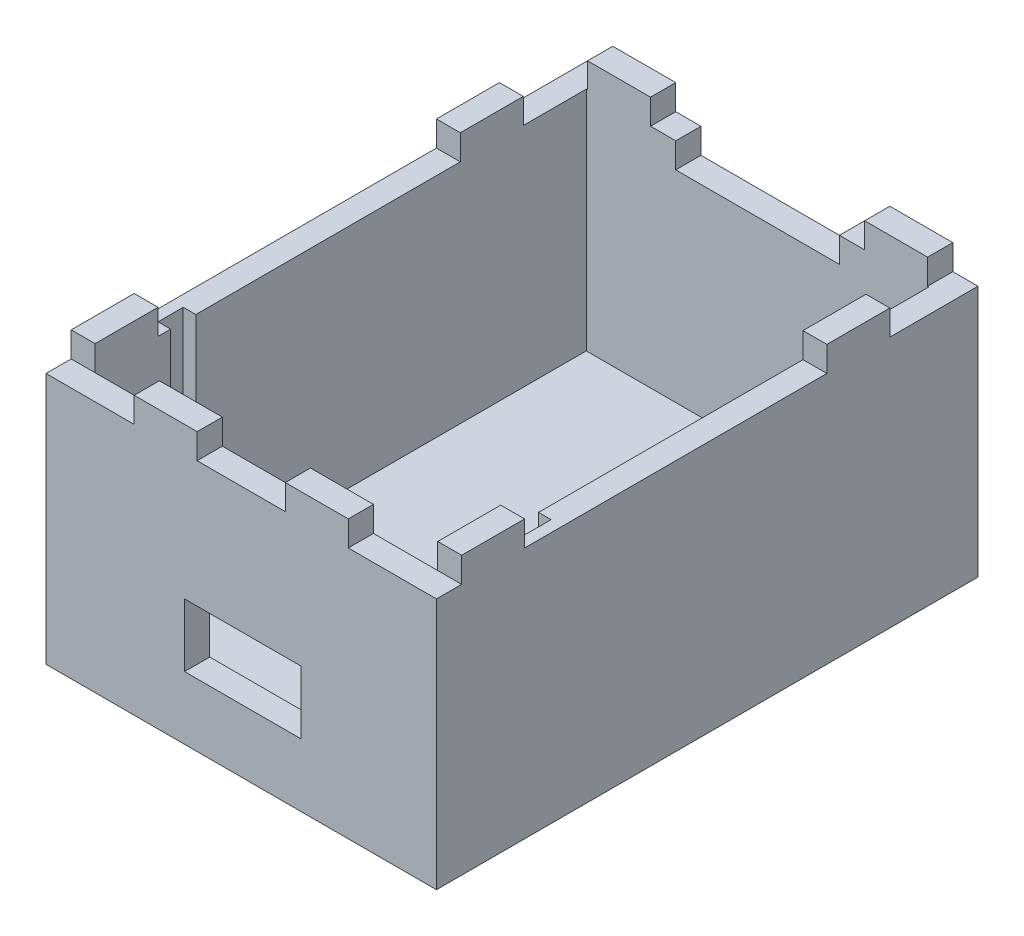
from build123d import *

# Parameters (mm, degrees)
SKETCH1_W           = 31
SKETCH1_H           = 43
BOSS_EXTRUDE1_DEPTH = 22
SKETCH2_W           = 27.20800305
SKETCH2_H           = 39
CUT_EXTRUDE1_DEPTH  = 20
SKETCH3_W           = 9.254141904
SKETCH3_H           = 5
CUT_EXTRUDE2_DEPTH  = 20
SKETCH4_W           = 7
SKETCH4_H           = 2
CUT_EXTRUDE3_DEPTH  = 2
SKETCH5_W           = 2
SKETCH5_H           = 2
CUT_EXTRUDE6_DEPTH  = 2
SKETCH6_W           = 5
SKETCH6_H           = 2
SKETCH6_W_2         = 19
CUT_EXTRUDE10_DEPTH = 34
SKETCH10_W          = 1
SKETCH10_H          = 2
CUT_EXTRUDE11_DEPTH = 18
SKETCH11_W          = 1
SKETCH11_H          = 2
CUT_EXTRUDE12_DEPTH = 15
SKETCH12_W          = 1
SKETCH12_H          = 2
BOSS_EXTRUDE3_DEPTH = 2


with BuildPart() as part:
    # Sketch1 → Boss-Extrude1 (new body)
    with BuildSketch(Plane(origin=(0, 0, 0), x_dir=(1, 0, 0), z_dir=(0, 1, 0))):
        Rectangle(SKETCH1_W, SKETCH1_H)
    extrude(amount=BOSS_EXTRUDE1_DEPTH)

    # Sketch2 → Cut-Extrude1 (cut)
    with BuildSketch(Plane(origin=(0, 22, 0), x_dir=(1, 0, 0), z_dir=(0, 1, 0))):
        Rectangle(SKETCH2_W, SKETCH2_H)
    extrude(amount=-CUT_EXTRUDE1_DEPTH, mode=Mode.SUBTRACT)

    # Sketch3 → Cut-Extrude2 (cut)
    with BuildSketch(Plane.XY.offset(21.5)):
        with Locations((0.126254012, 7.5)):
            Rectangle(SKETCH3_W, SKETCH3_H)
    extrude(amount=-CUT_EXTRUDE2_DEPTH, mode=Mode.SUBTRACT)

    # Sketch4 → Cut-Extrude3 (cut)
    with BuildSketch(Plane.XY.offset(21.5)):
        with Locations((-12, 21)):
            Rectangle(SKETCH4_W, SKETCH4_H)
        with Locations((0, 21)):
            Rectangle(SKETCH4_W, SKETCH4_H)
        with Locations((12, 21)):
            Rectangle(SKETCH4_W, SKETCH4_H)
    extrude(amount=-CUT_EXTRUDE3_DEPTH, mode=Mode.SUBTRACT)

    # Sketch5 → Cut-Extrude6 (cut)
    with BuildSketch(Plane(origin=(0, 0, -21.5), x_dir=(-1, 0, 0), z_dir=(0, 0, -1))):
        with Locations((14.5, 21)):
            Rectangle(SKETCH5_W, SKETCH5_H)
        Polygon((-8.5, 22), (-8.5, 20), (-6.500281768, 20), (6.499718232, 20), (8.5, 20), (8.5, 22), align=None)
        with Locations((-14.5, 21)):
            Rectangle(SKETCH5_W, SKETCH5_H)
        Polygon((6.499718232, 20), (-6.500281768, 20), (-6.500281768, 19.64343591), (-6.500281768, 18), (6.499718232, 18), align=None)
    extrude(amount=-CUT_EXTRUDE6_DEPTH, mode=Mode.SUBTRACT)

    # Sketch6 → Cut-Extrude10 (cut)
    with BuildSketch(Plane.ZY.offset(15.5)):
        with Locations((-17, 21)):
            Rectangle(SKETCH6_W, SKETCH6_H)
        with Locations((0, 21)):
            Rectangle(SKETCH6_W_2, SKETCH6_H)
        with Locations((12, 21)):
            Rectangle(SKETCH6_W, SKETCH6_H)
    extrude(amount=-CUT_EXTRUDE10_DEPTH, mode=Mode.SUBTRACT)

    # Sketch10 → Cut-Extrude11 (cut)
    with BuildSketch(Plane(origin=(0, 2, 0), x_dir=(1, 0, 0), z_dir=(0, 1, 0))):
        with Locations((14.104001525, -12.5)):
            Rectangle(SKETCH10_W, SKETCH10_H)
    extrude(amount=CUT_EXTRUDE11_DEPTH, mode=Mode.SUBTRACT)

    # Sketch11 → Cut-Extrude12 (cut)
    with BuildSketch(Plane(origin=(0, 20, 0), x_dir=(1, 0, 0), z_dir=(0, 1, 0))):
        with Locations((-14.104001525, -12.5)):
            Rectangle(SKETCH11_W, SKETCH11_H)
    extrude(amount=-CUT_EXTRUDE12_DEPTH, mode=Mode.SUBTRACT)

    # Sketch12 → Boss-Extrude3 (add)
    with BuildSketch(Plane(origin=(0, 2, 0), x_dir=(1, 0, 0), z_dir=(0, 1, 0))):
        with Locations((14.104001525, -12.5)):
            Rectangle(SKETCH12_W, SKETCH12_H)
    extrude(amount=BOSS_EXTRUDE3_DEPTH)


solid = part.part
